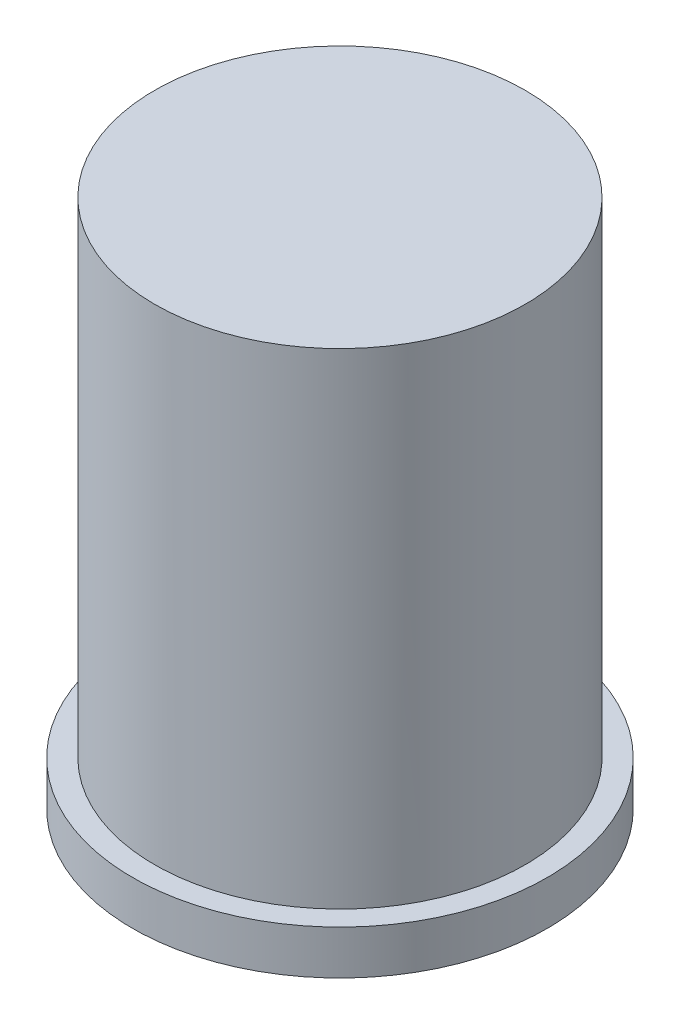
from build123d import *

# Parameters (mm, degrees)
SKETCH1_R           = 42
BOSS_EXTRUDE1_DEPTH = 120
SKETCH2_R           = 47
SKETCH2_R_2         = 42
BOSS_EXTRUDE2_DEPTH = 10


with BuildPart() as part:
    # Sketch1 → Boss-Extrude1 (new body)
    with BuildSketch(Plane(origin=(0, 0, 0), x_dir=(1, 0, 0), z_dir=(0, 1, 0))):
        Circle(SKETCH1_R)
    extrude(amount=BOSS_EXTRUDE1_DEPTH)

    # Sketch2 → Boss-Extrude2 (add)
    with BuildSketch(Plane.XZ):
        Circle(SKETCH2_R)
        Circle(SKETCH2_R_2, mode=Mode.SUBTRACT)
    extrude(amount=-BOSS_EXTRUDE2_DEPTH)


solid = part.part
